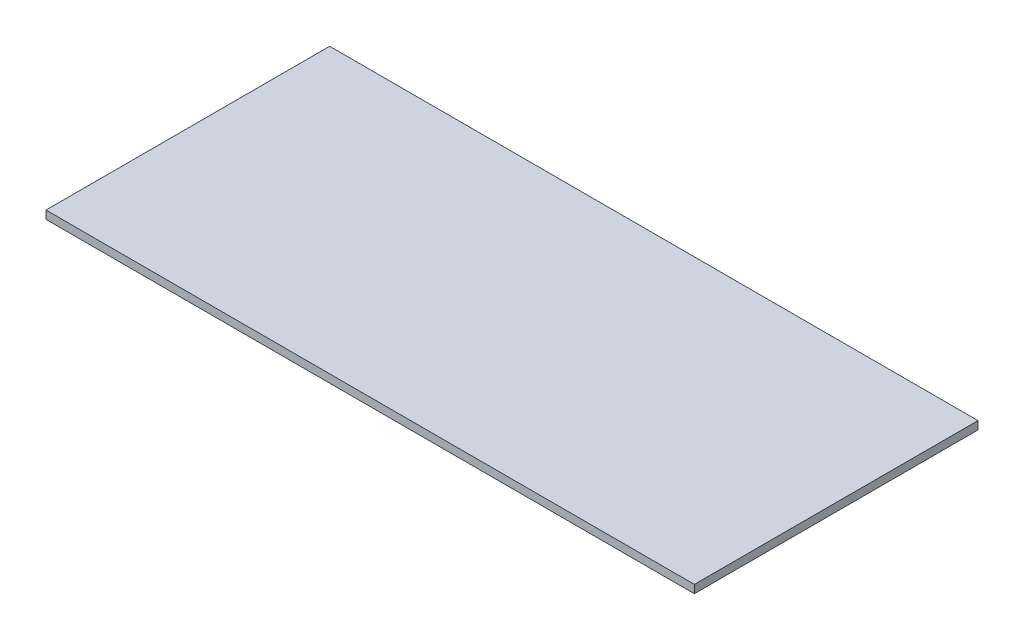
from build123d import *

# Parameters (mm, degrees)
SKETCH4_W           = 160
SKETCH4_H           = 70
BOSS_EXTRUDE2_DEPTH = 2


with BuildPart() as part:
    # Sketch4 → Boss-Extrude2 (new body)
    with BuildSketch(Plane(origin=(0, 0, 0), x_dir=(1, 0, 0), z_dir=(0, 1, 0))):
        Rectangle(SKETCH4_W, SKETCH4_H)
    extrude(amount=BOSS_EXTRUDE2_DEPTH)


solid = part.part
